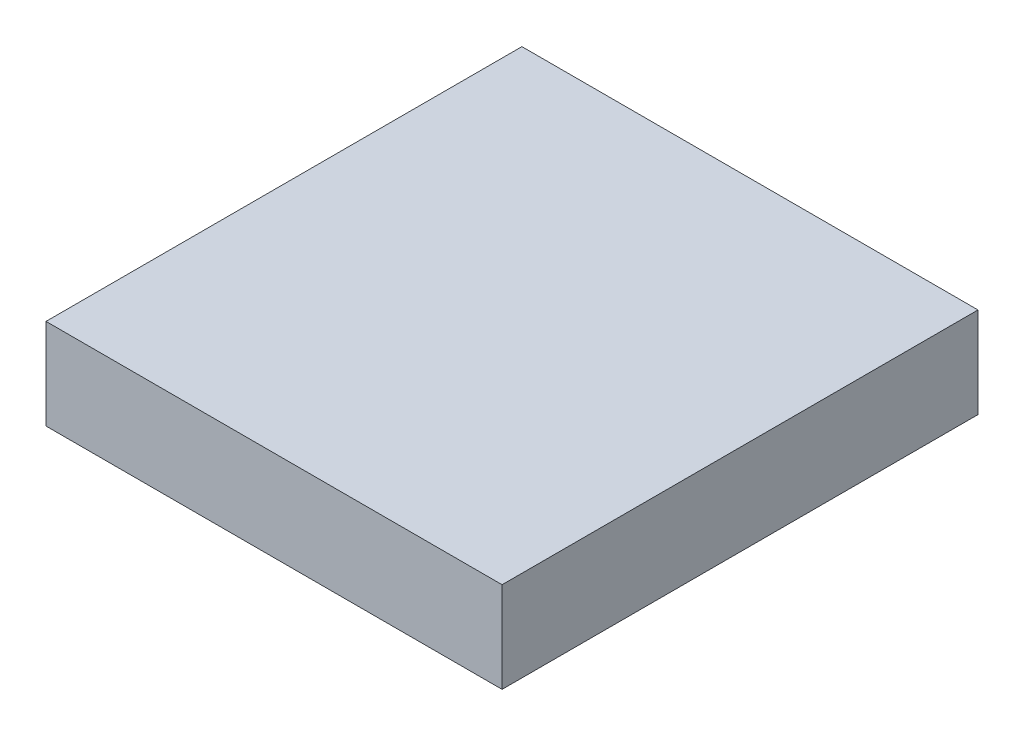
from build123d import *

# Parameters (mm, degrees)
SKETCH_1_W      = 16.1
SKETCH_1_H      = 16.8
EXTRUDE_1_DEPTH = 3.2


with BuildPart() as part:
    # Эскиз1 → Бобышка-Вытянуть1 (new body)
    with BuildSketch(Plane(origin=(0, 0, 0), x_dir=(1, 0, 0), z_dir=(0, 1, 0))):
        Rectangle(SKETCH_1_W, SKETCH_1_H)
    extrude(amount=EXTRUDE_1_DEPTH)


solid = part.part
